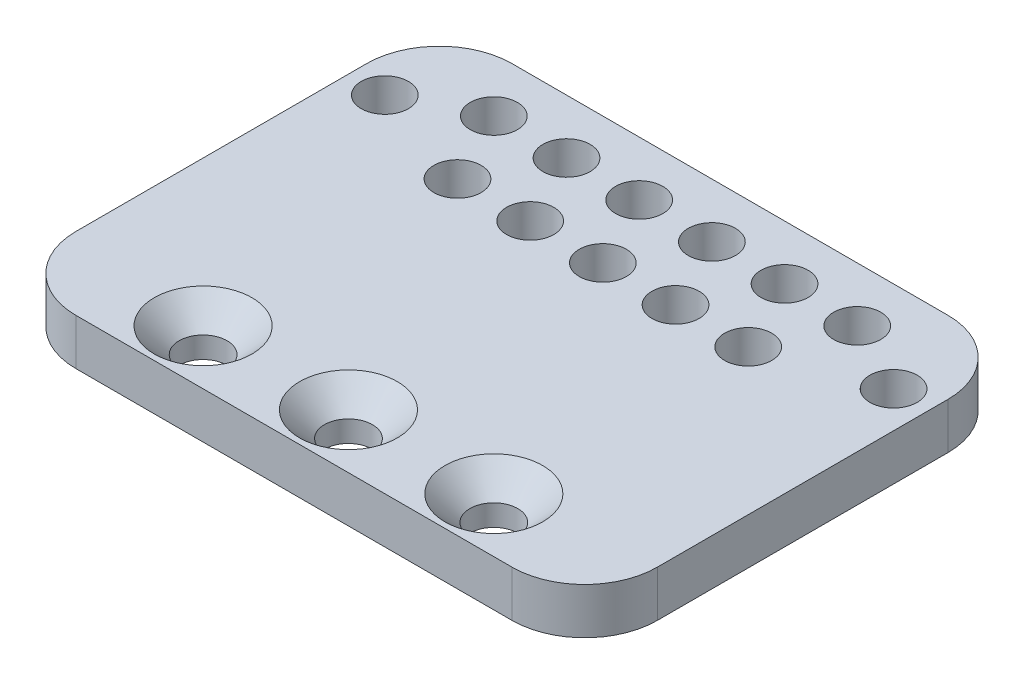
from build123d import *

# Parameters (mm, degrees)
SKETCH1_W                    = 80
SKETCH1_H                    = 60
SKETCH1_R                    = 3.1
SKETCH1_R_2                  = 3.25
BOSS_EXTRUDE1_DEPTH          = 6.35
FILLET1_R                    = 10
CSK_FOR_M6_SFHCS1_AT_2_COUNT = 2
CSK_FOR_M6_SFHCS1_AT_2_PITCH = 20
CSK_FOR_M6_SFHCS1_AT_3_COUNT = 2
CSK_FOR_M6_SFHCS1_AT_3_PITCH = 40


with BuildPart() as part:
    # Sketch1 → Boss-Extrude1 (new body)
    with BuildSketch(Plane(origin=(0, 0, 0), x_dir=(1, 0, 0), z_dir=(0, 1, 0))):
        with Locations((40, 30)):
            Rectangle(SKETCH1_W, SKETCH1_H)
        with Locations((40, 7.5)):
            Circle(SKETCH1_R, mode=Mode.SUBTRACT)
        with Locations((20, 7.5)):
            Circle(SKETCH1_R, mode=Mode.SUBTRACT)
        with Locations((60, 7.5)):
            Circle(SKETCH1_R, mode=Mode.SUBTRACT)
        with Locations((35, 52.5)):
            Circle(SKETCH1_R_2, mode=Mode.SUBTRACT)
        with Locations((45, 52.5)):
            Circle(SKETCH1_R_2, mode=Mode.SUBTRACT)
        with Locations((25, 52.5)):
            Circle(SKETCH1_R_2, mode=Mode.SUBTRACT)
        with Locations((30, 42.5)):
            Circle(SKETCH1_R_2, mode=Mode.SUBTRACT)
        with Locations((40, 42.5)):
            Circle(SKETCH1_R_2, mode=Mode.SUBTRACT)
        with Locations((50, 42.5)):
            Circle(SKETCH1_R_2, mode=Mode.SUBTRACT)
        with Locations((20, 42.5)):
            Circle(SKETCH1_R_2, mode=Mode.SUBTRACT)
        with Locations((15, 52.5)):
            Circle(SKETCH1_R_2, mode=Mode.SUBTRACT)
        with Locations((55, 52.5)):
            Circle(SKETCH1_R_2, mode=Mode.SUBTRACT)
        with Locations((65, 52.5)):
            Circle(SKETCH1_R_2, mode=Mode.SUBTRACT)
        with Locations((60, 42.5)):
            Circle(SKETCH1_R_2, mode=Mode.SUBTRACT)
        with Locations((75, 47.5)):
            Circle(SKETCH1_R_2, mode=Mode.SUBTRACT)
        with Locations((5, 47.5)):
            Circle(SKETCH1_R_2, mode=Mode.SUBTRACT)
    extrude(amount=BOSS_EXTRUDE1_DEPTH)

    # Fillet1
    fillet1_edges = [part.edges().sort_by_distance(p)[0] for p in [
        (0, 3.175, 0),
        (0, 3.175, -60),
        (80, 3.175, -60),
        (80, 3.175, 0),
    ]]
    fillet(fillet1_edges, radius=FILLET1_R)

    # Sketch3 → CSK for M6 SFHCS1 (revolve, cut)
    with BuildSketch(Plane(origin=(20, 6.35, -7.5), x_dir=(0, 0, 1), z_dir=(1, 0, 0))):
        Polygon((0, 0), (0, 6.35), (3.3, 6.35), (3.3, 3.42), (6.72, 0), align=None)
    csk_for_m6_sfhcs1 = revolve(axis=Axis((20, 12.7, -7.5), (0, -1, 0)), mode=Mode.SUBTRACT)

    # CSK for M6 SFHCS1 at 2: CSK for M6 SFHCS1 ×2
    with Locations(*[(i * CSK_FOR_M6_SFHCS1_AT_2_PITCH, 0, 0) for i in range(1, CSK_FOR_M6_SFHCS1_AT_2_COUNT)]):
        add(csk_for_m6_sfhcs1, mode=Mode.SUBTRACT)

    # CSK for M6 SFHCS1 at 3: CSK for M6 SFHCS1 ×2
    with Locations(*[(i * CSK_FOR_M6_SFHCS1_AT_3_PITCH, 0, 0) for i in range(1, CSK_FOR_M6_SFHCS1_AT_3_COUNT)]):
        add(csk_for_m6_sfhcs1, mode=Mode.SUBTRACT)


solid = part.part
